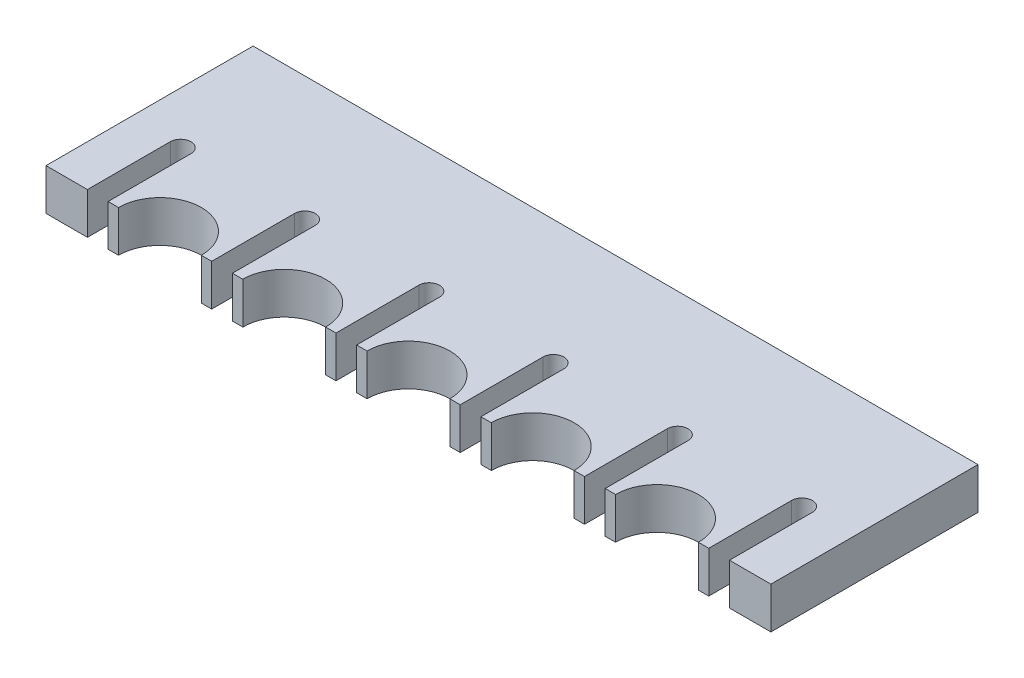
from build123d import *

# Parameters (mm, degrees)
BOSS_EXTRUDE1_DEPTH = 10


with BuildPart() as part:
    # Sketch2 → Boss-Extrude1 (new body)
    with BuildSketch(Plane(origin=(0, 0, 0), x_dir=(1, 0, 0), z_dir=(0, 1, 0))):
        with BuildLine():
            Line((-77.5, -25), (-77.5, -5))
            ThreePointArc((-77.5, -5), (-75, -2.5), (-72.5, -5))
            Line((-72.5, -5), (-72.5, -25))
            Line((-72.5, -25), (-70, -25))
            ThreePointArc((-70, -25), (-60, -15), (-50, -25))
            Line((-50, -25), (-47.5, -25))
            Line((-47.5, -25), (-47.5, -5))
            ThreePointArc((-47.5, -5), (-45, -2.5), (-42.5, -5))
            Line((-42.5, -5), (-42.5, -25))
            Line((-42.5, -25), (-40, -25))
            ThreePointArc((-40, -25), (-30, -15), (-20, -25))
            Line((-20, -25), (-17.5, -25))
            Line((-17.5, -25), (-17.5, -5))
            ThreePointArc((-17.5, -5), (-15, -2.5), (-12.5, -5))
            Line((-12.5, -5), (-12.5, -25))
            Line((-12.5, -25), (-10, -25))
            ThreePointArc((-10, -25), (0, -15), (10, -25))
            Line((10, -25), (12.5, -25))
            Line((12.5, -25), (12.5, -5))
            ThreePointArc((12.5, -5), (15, -2.5), (17.5, -5))
            Line((17.5, -5), (17.5, -25))
            Line((17.5, -25), (20, -25))
            ThreePointArc((20, -25), (30, -15), (40, -25))
            Line((40, -25), (42.5, -25))
            Line((42.5, -25), (42.5, -5))
            ThreePointArc((42.5, -5), (45, -2.5), (47.5, -5))
            Line((47.5, -5), (47.5, -25))
            Line((47.5, -25), (50, -25))
            ThreePointArc((50, -25), (60, -15), (70, -25))
            Line((70, -25), (72.5, -25))
            Line((72.5, -25), (72.5, -5))
            ThreePointArc((72.5, -5), (75, -2.5), (77.5, -5))
            Line((77.5, -5), (77.5, -25))
            Line((77.5, -25), (87.5, -25))
            Line((87.5, -25), (87.5, 25))
            Line((87.5, 25), (-87.5, 25))
            Line((-87.5, 25), (-87.5, -25))
            Line((-87.5, -25), (-77.5, -25))
        make_face()
    extrude(amount=BOSS_EXTRUDE1_DEPTH)


solid = part.part
